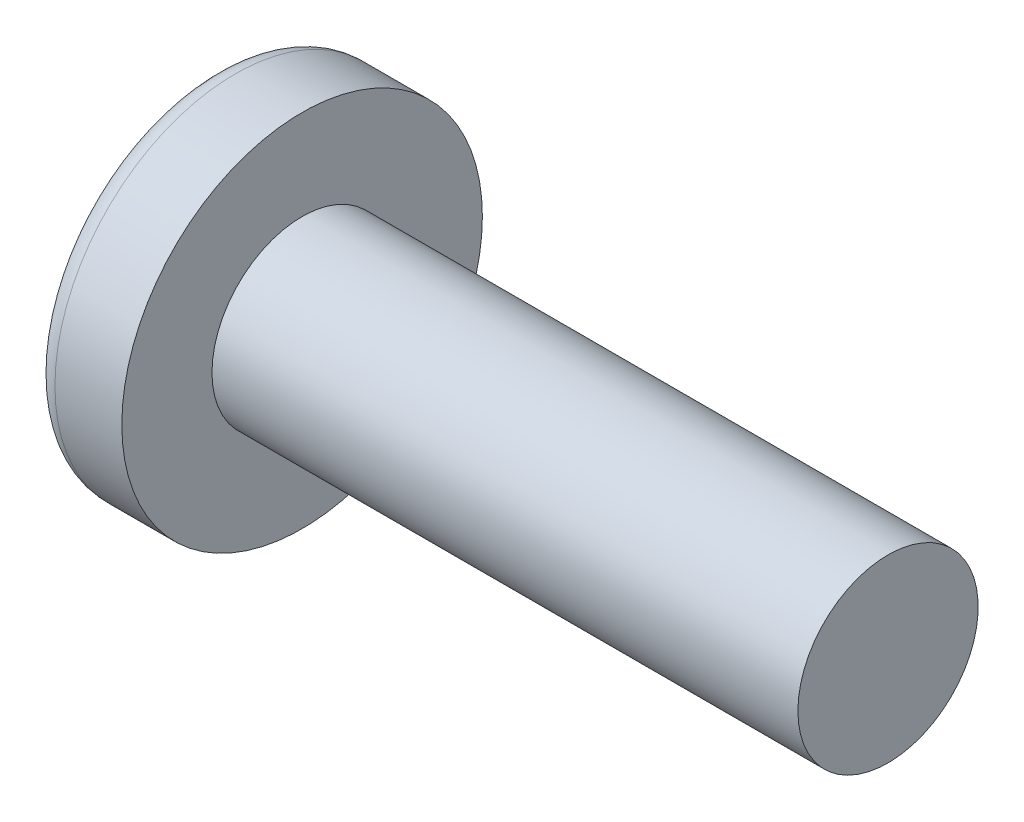
from build123d import *

# Parameters (mm, degrees)
SKETCH3_W         = 0.93
SKETCH3_H         = 4.4
SKETCH4_W         = 0.465
SKETCH4_H         = 0.465
CIRPATTERN1_COUNT = 2
CIRPATTERN1_ANGLE = 90


with BuildPart() as part:
    # BodySke → Base-Revolve (revolve)
    with BuildSketch(Plane.XY):
        with BuildLine():
            Line((3.1, 2), (3.1, 4))
            Line((3.1, 4), (1.616353821, 4))
            ThreePointArc((1.616353821, 4), (1.397629036, 3.947269784), (1.226960106, 3.800664452))
            ThreePointArc((1.226960106, 3.800664452), (0.314340807, 1.996902688), (0, 0))
            Line((0, 0), (16.1, 0))
            Line((16.1, 0), (16.1, 2))
            Line((16.1, 2), (3.1, 2))
        make_face()
    revolve(axis=Axis((-25.4, 0, 0), (1, 0, 0)))

    # Sketch3 → Cut-Loft1 section 0
    with BuildSketch(Plane(origin=(0, 0, 0), x_dir=(0, 0, -1), z_dir=(1, 0, 0))):
        Rectangle(SKETCH3_W, SKETCH3_H)
    # Sketch4 → Cut-Loft1 section 1
    with BuildSketch(Plane(origin=(2.45, 0, 0), x_dir=(0, 0, -1), z_dir=(1, 0, 0))):
        Rectangle(SKETCH4_W, SKETCH4_H)
    cut_loft1 = loft(mode=Mode.SUBTRACT)

    # CirPattern1: Cut-Loft1 ×2 about axis
    cirpattern1_axis = Axis((0, 0, 0), (1, 0, 0))
    for i in range(1, CIRPATTERN1_COUNT):
        add(cut_loft1.rotate(cirpattern1_axis, i * CIRPATTERN1_ANGLE / (CIRPATTERN1_COUNT - 1)), mode=Mode.SUBTRACT)


solid = part.part
